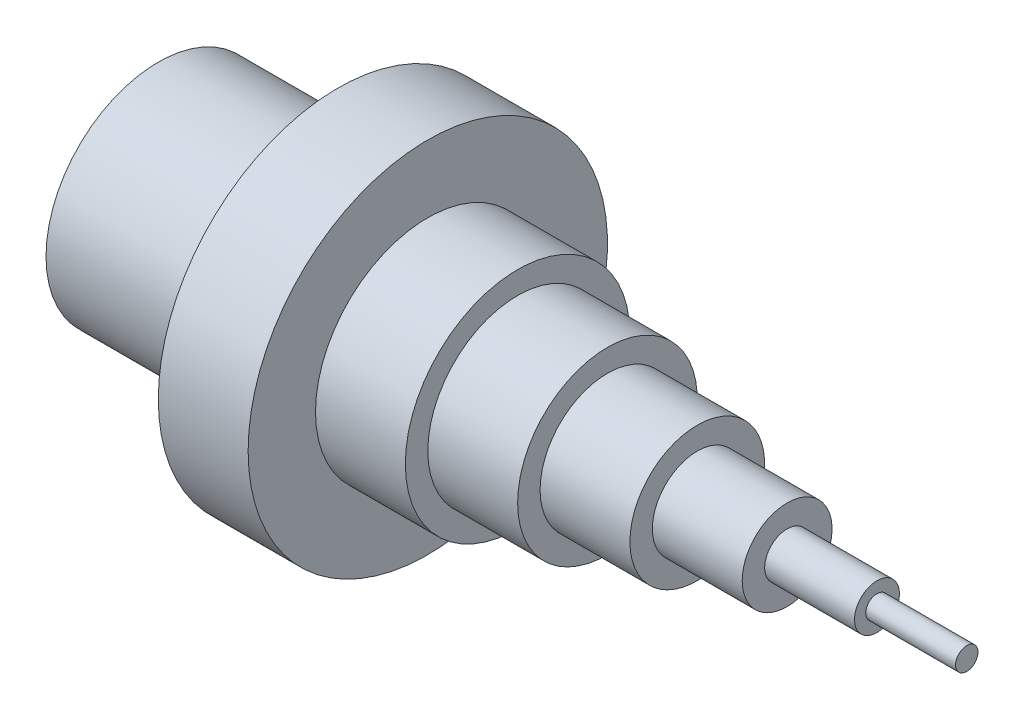
from build123d import *

# Parameters (mm, degrees)
SKETCH2_R          = 20
CUT_EXTRUDE1_DEPTH = 40


with BuildPart() as part:
    # Sketch1 → Revolve1 (revolve)
    with BuildSketch(Plane.XY, mode=Mode.PRIVATE) as revolve1_sk:
        Polygon((0, 0), (0, 25), (40, 25), (40, 40), (60, 40), (60, 25), (80, 25), (80, 20), (100, 20), (100, 15), (120, 15), (120, 10), (140, 10), (140, 5), (160, 5), (160, 2.5), (180, 2.5), (180, 0), align=None)
    revolve(revolve1_sk.sketch.rotate(Axis((0, 0, 0), (1, 0, 0)), 90), axis=Axis((0, 0, 0), (1, 0, 0)))  # turned: the seam where the file's is

    # Sketch2 → Cut-Extrude1 (cut)
    with BuildSketch(Plane.ZY):
        Circle(SKETCH2_R)
    extrude(amount=-CUT_EXTRUDE1_DEPTH, mode=Mode.SUBTRACT)


solid = part.part
